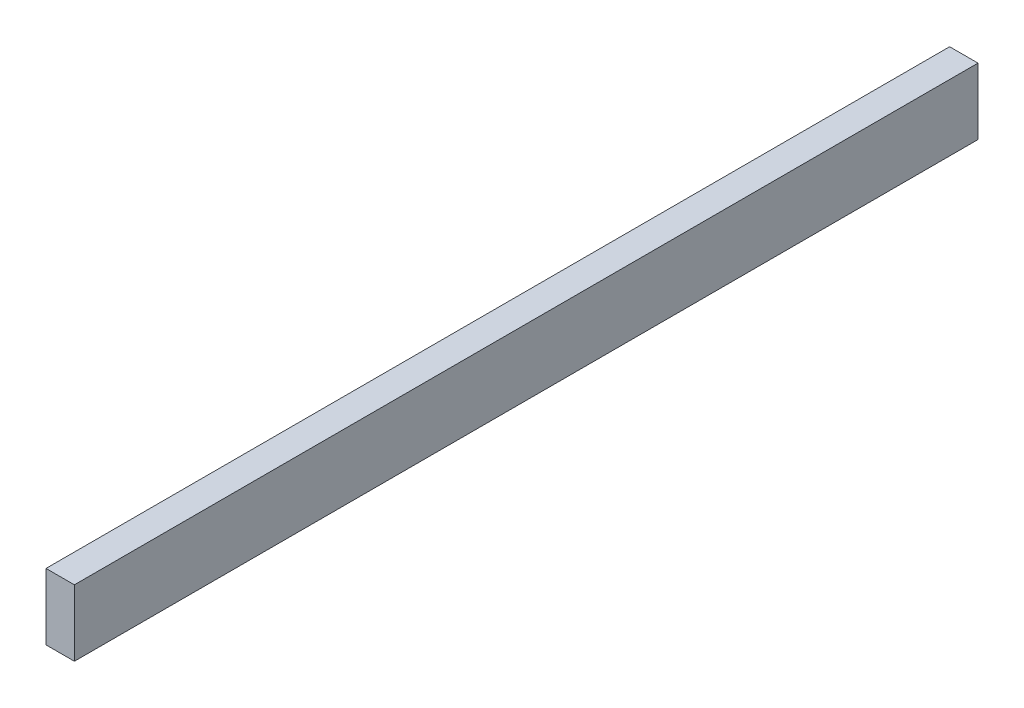
from build123d import *

# Parameters (mm, degrees)
SKETCH1_W           = 38.1
SKETCH1_H           = 88.9
BOSS_EXTRUDE1_DEPTH = 1212.85


with BuildPart() as part:
    # Sketch1 → Boss-Extrude1 (new body)
    with BuildSketch(Plane.XY):
        with Locations((2.094373614, -6.915287221)):
            Rectangle(SKETCH1_W, SKETCH1_H)
    extrude(amount=BOSS_EXTRUDE1_DEPTH)


solid = part.part
